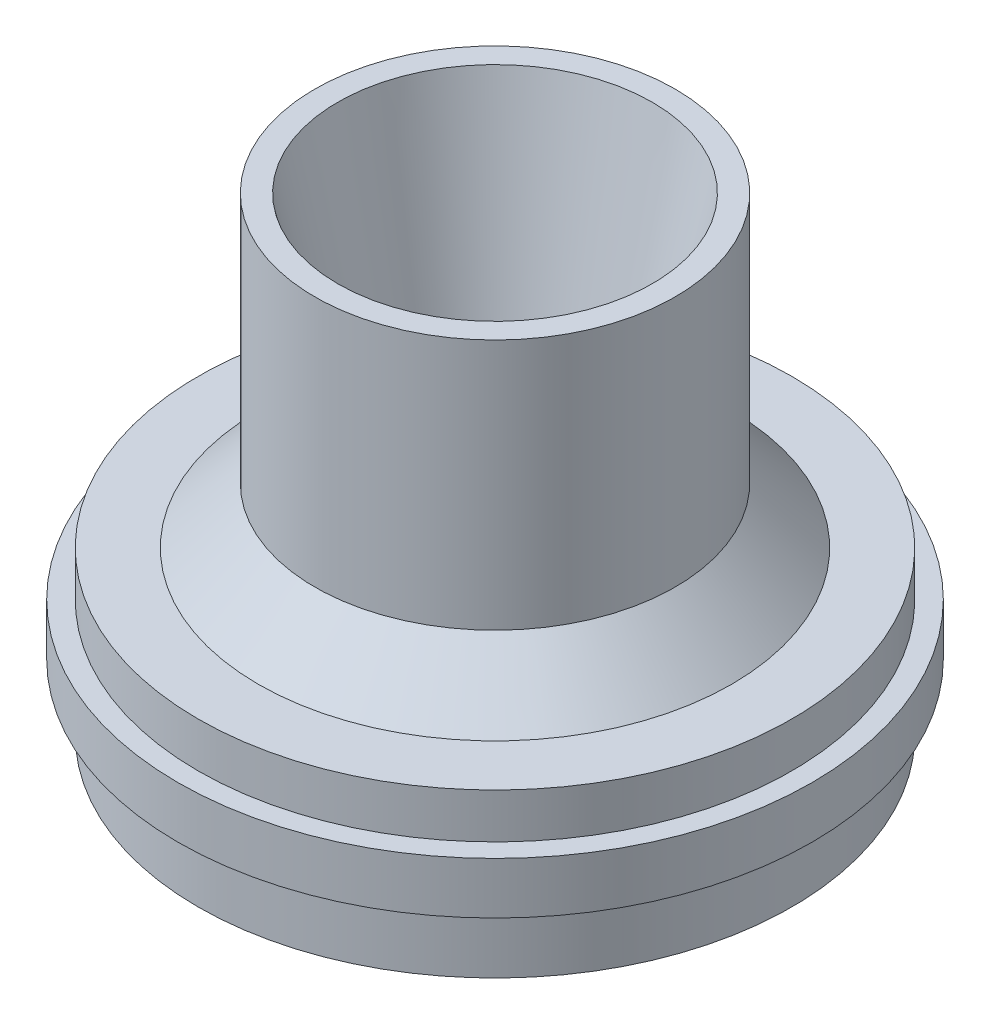
from build123d import *


with BuildPart() as part:
    # Sketch1 → Revolve1 (revolve)
    with BuildSketch(Plane.XY):
        Polygon((-22.7457, 25.4), (-13.589, -17.3482), (-13.589, -29.2862), (-40.513, -42.5704), (-42.926, -42.5704), (-42.926, -32.9946), (-45.847, -32.9946), (-45.847, -25.527), (-42.926, -25.527), (-42.926, -19.0246), (-34.2265, -19.0246), (-26.0477, -10.9474), (-26.0477, 25.4), align=None)
    revolve(axis=Axis((0, 0, 0), (0, 1, 0)))


solid = part.part
